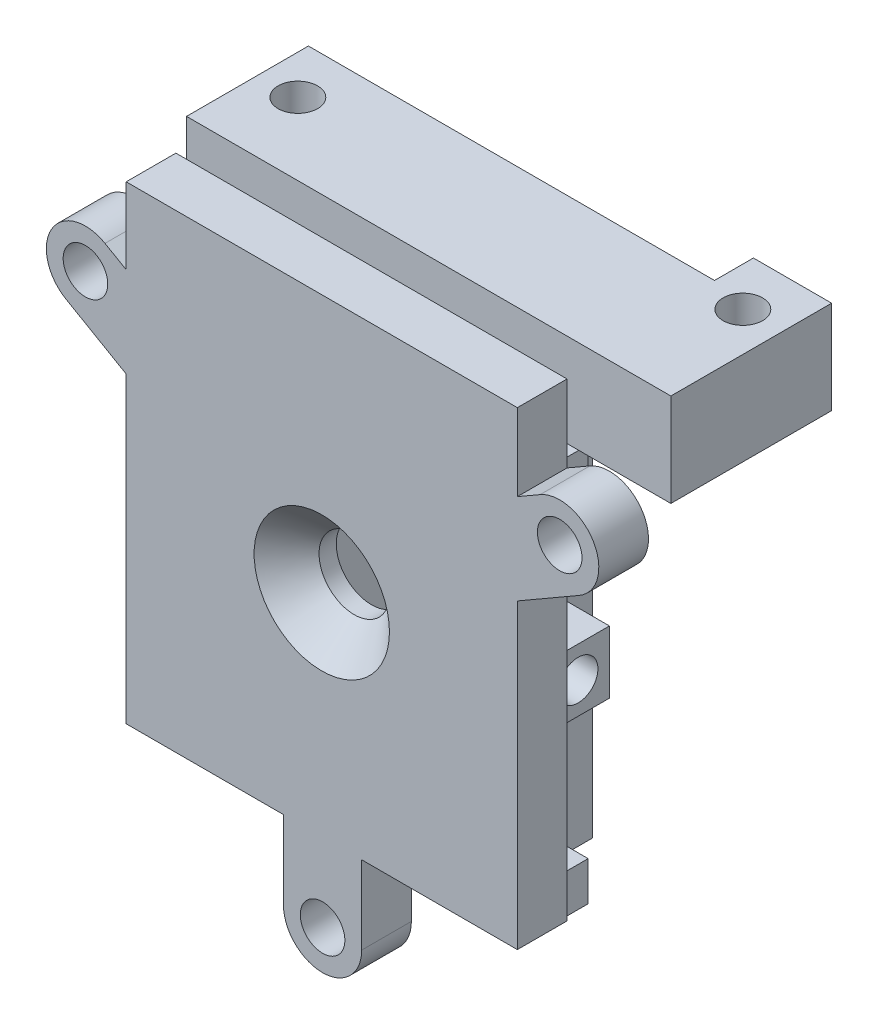
from build123d import *

# Parameters (mm, degrees)
SKETCH1_R                                       = 2.85
BOSS_EXTRUDE1_DEPTH                             = 6.35
SKETCH2_W                                       = 25.4
SKETCH2_H                                       = 69.5
SKETCH2_W_2                                     = 14.7
SKETCH2_H_2                                     = 52.8
BOSS_EXTRUDE2_DEPTH                             = 15.578435
CSK_FOR_M8_FLAT_HEAD_MACHINE_SCREW1_D           = 9
CSK_FOR_M8_FLAT_HEAD_MACHINE_SCREW1_DEPTH       = 17.5
CSK_FOR_M8_FLAT_HEAD_MACHINE_SCREW1_CSINK_D     = 17.3
CSK_FOR_M8_FLAT_HEAD_MACHINE_SCREW1_CSINK_ANGLE = 90
CSK_FOR_M8_FLAT_HEAD_MACHINE_SCREW1_TIP         = 2.703872786
SKETCH6_W                                       = 15.578435
SKETCH6_H                                       = 11.9
BOSS_EXTRUDE3_DEPTH                             = 25.572145
SKETCH7_W                                       = 15.578435
SKETCH7_H                                       = 11.9
BOSS_EXTRUDE4_DEPTH                             = 10.937286
SKETCH8_R                                       = 2.5273
CUT_EXTRUDE1_DEPTH                              = 7
SKETCH9_W                                       = 10
SKETCH9_H                                       = 11.9
BOSS_EXTRUDE5_DEPTH                             = 4.972688
SKETCH10_R                                      = 2.5273
CUT_EXTRUDE2_DEPTH                              = 7
SKETCH11_W                                      = 5.3384196
SKETCH11_H                                      = 10
BOSS_EXTRUDE6_DEPTH                             = 5.35
SKETCH14_W                                      = 5.35
SKETCH14_H                                      = 10
CUT_EXTRUDE4_DEPTH                              = 5.33842
SKETCH15_W                                      = 5
SKETCH15_H                                      = 5
SKETCH15_W_2                                    = 8
SKETCH15_H_2                                    = 8
BOSS_EXTRUDE7_DEPTH                             = 8
SKETCH16_R                                      = 2.5273
CUT_EXTRUDE5_DEPTH                              = 7


with BuildPart() as part:
    # Sketch1 → Boss-Extrude1 (new body)
    with BuildSketch(Plane.XY):
        with BuildLine():
            Line((-5, 30), (5, 30))
            Line((5, 30), (25, 30))
            Line((25, 30), (25, 20.148215542))
            Line((25, 20.148215542), (27.91315613, 21.830127018))
            ThreePointArc((27.91315613, 21.830127018), (34.743283149, 19.999999999), (32.91315613, 13.16987298))
            Line((32.91315613, 13.16987298), (25, 8.601210158))
            Line((25, 8.601210158), (25, -30))
            Line((25, -30), (5.102267, -30))
            Line((5.102267, -30), (5.102267, -40))
            ThreePointArc((5.102267, -40), (0.102267, -45), (-4.897733, -40))
            Line((-4.897733, -40), (-4.897733, -30))
            Line((-4.897733, -30), (-25, -30))
            Line((-25, -30), (-25, 8.719297918))
            Line((-25, 8.719297918), (-32.70862213, 13.16987298))
            ThreePointArc((-32.70862213, 13.16987298), (-34.538749149, 19.999999999), (-27.70862213, 21.830127018))
            Line((-27.70862213, 21.830127018), (-25, 20.266303302))
            Line((-25, 20.266303302), (-25, 30))
            Line((-25, 30), (-5, 30))
        make_face()
        with Locations((0.102267, -40)):
            Circle(SKETCH1_R, mode=Mode.SUBTRACT)
        with Locations((30.41315613, 17.499999999)):
            Circle(SKETCH1_R, mode=Mode.SUBTRACT)
        with Locations((-30.20862213, 17.499999999)):
            Circle(SKETCH1_R, mode=Mode.SUBTRACT)
    extrude(amount=BOSS_EXTRUDE1_DEPTH)

    # Sketch2 → Boss-Extrude2 (add)
    with BuildSketch(Plane(origin=(0, 0, 0), x_dir=(-1, 0, 0), z_dir=(0, 0, -1))):
        Rectangle(SKETCH2_W, SKETCH2_H)
        with Locations((0, -3)):
            Rectangle(SKETCH2_W_2, SKETCH2_H_2, mode=Mode.SUBTRACT)
    extrude(amount=BOSS_EXTRUDE2_DEPTH)

    # CSK for M8 Flat Head Machine Screw1
    with Locations(Plane.XY.offset(6.35)):
        with Locations((0, -3)):
            CounterSinkHole(CSK_FOR_M8_FLAT_HEAD_MACHINE_SCREW1_D / 2, CSK_FOR_M8_FLAT_HEAD_MACHINE_SCREW1_CSINK_D / 2, depth=CSK_FOR_M8_FLAT_HEAD_MACHINE_SCREW1_DEPTH, counter_sink_angle=CSK_FOR_M8_FLAT_HEAD_MACHINE_SCREW1_CSINK_ANGLE)
            with Locations((0, 0, -(CSK_FOR_M8_FLAT_HEAD_MACHINE_SCREW1_DEPTH + CSK_FOR_M8_FLAT_HEAD_MACHINE_SCREW1_TIP / 2))):  # 118° drill point
                Cone(0, CSK_FOR_M8_FLAT_HEAD_MACHINE_SCREW1_D / 2, CSK_FOR_M8_FLAT_HEAD_MACHINE_SCREW1_TIP, mode=Mode.SUBTRACT)

    # Sketch6 → Boss-Extrude3 (add)
    with BuildSketch(Plane(origin=(12.7, 0, 0), x_dir=(0, 0, -1), z_dir=(1, 0, 0))):
        with Locations((7.7892175, 28.8)):
            Rectangle(SKETCH6_W, SKETCH6_H)
    extrude(amount=BOSS_EXTRUDE3_DEPTH)

    # Sketch7 → Boss-Extrude4 (add)
    with BuildSketch(Plane.ZY.offset(12.7)):
        with Locations((-7.7892175, 28.8)):
            Rectangle(SKETCH7_W, SKETCH7_H)
    extrude(amount=BOSS_EXTRUDE4_DEPTH)

    # Sketch8 → Cut-Extrude1 (cut)
    with BuildSketch(Plane(origin=(0, 34.75, 0), x_dir=(1, 0, 0), z_dir=(0, 1, 0))):
        with Locations((-18.637286, 9.228435)):
            Circle(SKETCH8_R)
    extrude(amount=-CUT_EXTRUDE1_DEPTH, mode=Mode.SUBTRACT)

    # Sketch9 → Boss-Extrude5 (add)
    with BuildSketch(Plane(origin=(0, 0, -15.578435), x_dir=(-1, 0, 0), z_dir=(0, 0, -1))):
        with Locations((-33.272145, 28.8)):
            Rectangle(SKETCH9_W, SKETCH9_H)
    extrude(amount=BOSS_EXTRUDE5_DEPTH)

    # Sketch10 → Cut-Extrude2 (cut)
    with BuildSketch(Plane(origin=(0, 34.75, 0), x_dir=(1, 0, 0), z_dir=(0, 1, 0))):
        with Locations((33.272145, 14.201123)):
            Circle(SKETCH10_R)
    extrude(amount=-CUT_EXTRUDE2_DEPTH, mode=Mode.SUBTRACT)

    # Sketch11 → Boss-Extrude6 (add)
    with BuildSketch(Plane(origin=(12.7, 0, 0), x_dir=(0, 0, -1), z_dir=(1, 0, 0))):
        with Locations((18.2476448, -8.175)):
            Rectangle(SKETCH11_W, SKETCH11_H)
    extrude(amount=-BOSS_EXTRUDE6_DEPTH)

    # Sketch14 → Cut-Extrude4 (cut)
    with BuildSketch(Plane(origin=(0, 0, -20.9168546), x_dir=(-1, 0, 0), z_dir=(0, 0, -1))):
        with Locations((-10.025, -8.175)):
            Rectangle(SKETCH14_W, SKETCH14_H)
    extrude(amount=-CUT_EXTRUDE4_DEPTH, mode=Mode.SUBTRACT)

    # Sketch15 → Boss-Extrude7 (add)
    with BuildSketch(Plane(origin=(12.7, 0, 0), x_dir=(0, 0, -1), z_dir=(1, 0, 0))):
        with Locations((4.5, 14.55)):
            Rectangle(SKETCH15_W, SKETCH15_H)
        with Locations((4.5, -31.25)):
            Rectangle(SKETCH15_W, SKETCH15_H)
        with Locations((5.72, -8.35)):
            Rectangle(SKETCH15_W_2, SKETCH15_H_2)
    extrude(amount=BOSS_EXTRUDE7_DEPTH)

    # Sketch16 → Cut-Extrude5 (cut)
    with BuildSketch(Plane(origin=(20.7, 0, 0), x_dir=(0, 0, -1), z_dir=(1, 0, 0))):
        with Locations((5.72, -8.35)):
            Circle(SKETCH16_R)
    extrude(amount=-CUT_EXTRUDE5_DEPTH, mode=Mode.SUBTRACT)


solid = part.part
